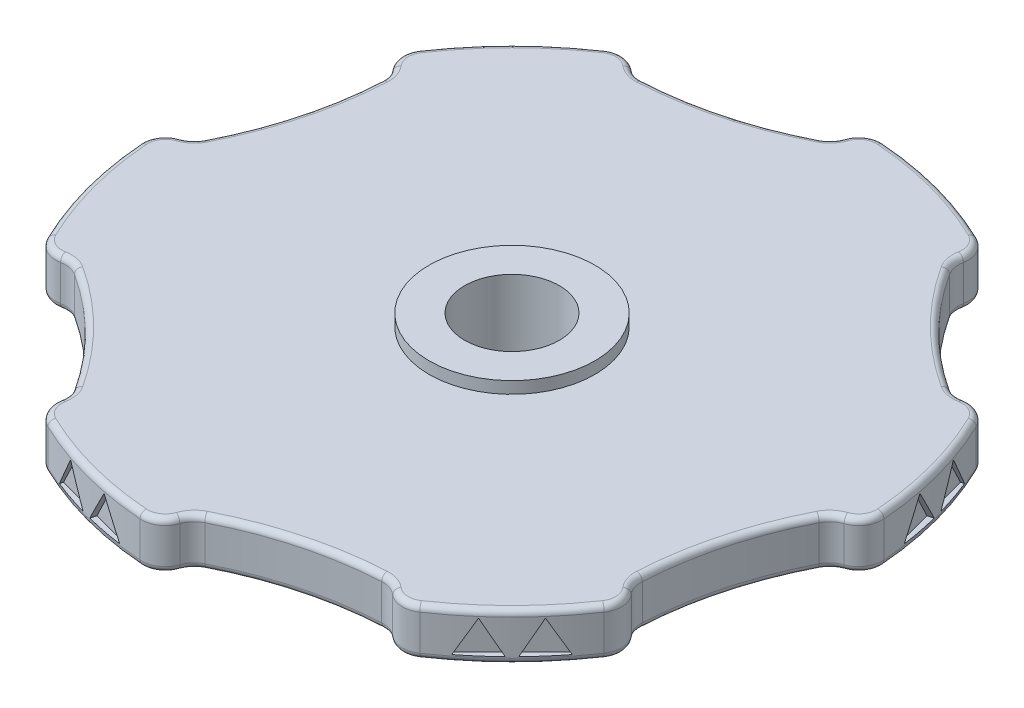
from build123d import *

# Parameters (mm, degrees)
EXTRUDE_2_DEPTH          = 4
FILLET_2_R               = 2
FILLET_1_R               = 0.5
SKETCH_2_R               = 4
CUT_EXTRUDE_1_DEPTH      = 5.0000001
EXTRUDE_START            = -5
SKETCH_4_R               = 7
SKETCH_4_R_2             = 4
EXTRUDE_3_DEPTH          = 6
CUT_EXTRUDE_2_DEPTH      = 0.5
PATTERN_CIRCULAR_3_COUNT = 6


with BuildPart() as part:
    # 草图1 → 凸台-拉伸2 (new body)
    with BuildSketch(Plane(origin=(0, 0, 0), x_dir=(1, 0, 0), z_dir=(0, 1, 0))):
        with BuildLine():
            ThreePointArc((-23.613697296, -13.633374491), (-25.201696191, -13.812934862), (-26.414260376, -12.7719399))
            ThreePointArc((-26.414260376, -12.7719399), (-28.340263743, -7.593750783), (-29.261390457, -2.146305779))
            ThreePointArc((-29.261390457, -2.146305779), (-28.731776551, -0.638495604), (-27.266748981, 0))
            Line((-27.266748981, 0), (0, 0))
            Line((0, 0), (-23.613697296, -13.633374491))
        make_face()
        with BuildLine():
            Line((0, 0), (-23.613697296, -13.633374491))
            ThreePointArc((-23.613697296, -13.633374491), (-18.014452987, -18.014452987), (-13.633374491, -23.613697296))
            Line((-13.633374491, -23.613697296), (0, 0))
        make_face()
        with BuildLine():
            Line((0, 0), (-13.633374491, -23.613697296))
            ThreePointArc((-13.633374491, -23.613697296), (-13.812934862, -25.201696191), (-12.7719399, -26.414260376))
            ThreePointArc((-12.7719399, -26.414260376), (-7.593750783, -28.340263743), (-2.146305779, -29.261390457))
            ThreePointArc((-2.146305779, -29.261390457), (-0.638495604, -28.731776551), (0, -27.266748981))
            Line((0, -27.266748981), (0, 0))
        make_face()
        with BuildLine():
            Line((0, 0), (0, -27.266748981))
            ThreePointArc((0, -27.266748981), (6.593747429, -24.608200416), (13.633374491, -23.613697296))
            Line((13.633374491, -23.613697296), (0, 0))
        make_face()
        with BuildLine():
            ThreePointArc((23.613697296, -13.633374491), (24.563200587, -14.918841688), (24.267954597, -16.489450558))
            ThreePointArc((24.267954597, -16.489450558), (20.74651296, -20.74651296), (16.489450558, -24.267954597))
            ThreePointArc((16.489450558, -24.267954597), (14.918841688, -24.563200587), (13.633374491, -23.613697296))
            Line((13.633374491, -23.613697296), (0, 0))
            Line((0, 0), (23.613697296, -13.633374491))
        make_face()
        with BuildLine():
            Line((0, 0), (23.613697296, -13.633374491))
            ThreePointArc((23.613697296, -13.633374491), (24.608200416, -6.593747429), (27.266748981, 0))
            Line((27.266748981, 0), (0, 0))
        make_face()
        with BuildLine():
            ThreePointArc((23.613697296, 13.633374491), (25.201696191, 13.812934862), (26.414260376, 12.7719399))
            ThreePointArc((26.414260376, 12.7719399), (28.340263743, 7.593750783), (29.261390457, 2.146305779))
            ThreePointArc((29.261390457, 2.146305779), (28.731776551, 0.638495604), (27.266748981, 0))
            Line((27.266748981, 0), (0, 0))
            Line((0, 0), (23.613697296, 13.633374491))
        make_face()
        with BuildLine():
            Line((0, 0), (23.613697296, 13.633374491))
            ThreePointArc((23.613697296, 13.633374491), (18.014452987, 18.014452987), (13.633374491, 23.613697296))
            Line((13.633374491, 23.613697296), (0, 0))
        make_face()
        with BuildLine():
            ThreePointArc((0, 27.266748981), (0.638495604, 28.731776551), (2.146305779, 29.261390457))
            ThreePointArc((2.146305779, 29.261390457), (7.593750783, 28.340263743), (12.7719399, 26.414260376))
            ThreePointArc((12.7719399, 26.414260376), (13.812934862, 25.201696191), (13.633374491, 23.613697296))
            Line((13.633374491, 23.613697296), (0, 0))
            Line((0, 0), (0, 27.266748981))
        make_face()
        with BuildLine():
            Line((0, 0), (0, 27.266748981))
            ThreePointArc((0, 27.266748981), (-6.593747429, 24.608200416), (-13.633374491, 23.613697296))
            Line((-13.633374491, 23.613697296), (0, 0))
        make_face()
        with BuildLine():
            ThreePointArc((-23.613697296, 13.633374491), (-24.563200587, 14.918841688), (-24.267954597, 16.489450558))
            ThreePointArc((-24.267954597, 16.489450558), (-20.74651296, 20.74651296), (-16.489450558, 24.267954597))
            ThreePointArc((-16.489450558, 24.267954597), (-14.918841688, 24.563200587), (-13.633374491, 23.613697296))
            Line((-13.633374491, 23.613697296), (0, 0))
            Line((0, 0), (-23.613697296, 13.633374491))
        make_face()
        with BuildLine():
            Line((0, 0), (-23.613697296, 13.633374491))
            ThreePointArc((-23.613697296, 13.633374491), (-24.608200416, 6.593747429), (-27.266748981, 0))
            Line((-27.266748981, 0), (0, 0))
        make_face()
    extrude(amount=EXTRUDE_2_DEPTH)

    # 圆角2
    fillet_2_edges = [part.edges().sort_by_distance(p)[0] for p in [
        (23.613697296, 2, 13.633374491),
        (13.633374491, 2, 23.613697296),
        (0, 2, 27.266748981),
        (-13.633374491, 2, 23.613697296),
        (-23.613697296, 2, 13.633374491),
        (-27.266748981, 2, 0),
        (-23.613697296, 2, -13.633374491),
        (-13.633374491, 2, -23.613697296),
        (0, 2, -27.266748981),
        (13.633374491, 2, -23.613697296),
        (23.613697296, 2, -13.633374491),
        (27.266748981, 2, 0),
    ]]
    fillet(fillet_2_edges, radius=FILLET_2_R)

    # 圆角1
    fillet_1_edges = [part.edges().sort_by_distance(p)[0] for p in [
        (24.608200416, 0, 6.593747429),
        (24.608200416, 4, 6.593747429),
        (24.610469164, 0, 15.251837855),
        (24.610469164, 4, 15.251837855),
        (13.402973244, 0, 23.753233217),
        (13.402973244, 4, 23.753233217),
        (0.269301293, 0, 27.27239001),
        (0.269301293, 4, 27.27239001),
        (-13.869416766, 0, 23.483931924),
        (-13.869416766, 4, 23.483931924),
        (-23.483931924, 0, 13.869416766),
        (20.74651296, 4, 20.74651296),
        (-23.483931924, 4, 13.869416766),
        (-27.27239001, 0, -0.269301293),
        (-27.27239001, 4, -0.269301293),
        (-23.753233217, 0, -13.402973244),
        (-23.753233217, 4, -13.402973244),
        (-13.402973244, 0, -23.753233217),
        (-13.402973244, 4, -23.753233217),
        (-0.269301293, 0, -27.27239001),
        (-0.269301293, 4, -27.27239001),
        (13.869416766, 0, -23.483931924),
        (13.869416766, 4, -23.483931924),
        (23.483931924, 0, -13.869416766),
        (23.483931924, 4, -13.869416766),
        (27.27239001, 0, 0.269301293),
        (27.27239001, 4, 0.269301293),
        (23.753233217, 0, 13.402973244),
        (23.753233217, 4, 13.402973244),
        (28.340263743, 4, -7.593750783),
        (20.74651296, 0, 20.74651296),
        (-7.593750783, 0, 28.340263743),
        (-28.340263743, 0, 7.593750783),
        (-20.74651296, 0, -20.74651296),
        (7.593750783, 0, -28.340263743),
        (7.593750783, 4, -28.340263743),
        (28.340263743, 0, -7.593750783),
        (-20.74651296, 4, -20.74651296),
        (-28.340263743, 4, 7.593750783),
        (15.251837855, 0, 24.610469164),
        (15.251837855, 4, 24.610469164),
        (6.593747429, 0, 24.608200416),
        (6.593747429, 4, 24.608200416),
        (-0.903244454, 0, 28.939210423),
        (-0.903244454, 4, 28.939210423),
        (-13.687372568, 0, 25.513713619),
        (-13.687372568, 4, 25.513713619),
        (-18.014452987, 0, 18.014452987),
        (-18.014452987, 4, 18.014452987),
        (-25.513713619, 0, 13.687372568),
        (-25.513713619, 4, 13.687372568),
        (-28.939210423, 0, 0.903244454),
        (-28.939210423, 4, 0.903244454),
        (-24.608200416, 0, -6.593747429),
        (-24.608200416, 4, -6.593747429),
        (-24.610469164, 0, -15.251837855),
        (-24.610469164, 4, -15.251837855),
        (-15.251837855, 0, -24.610469164),
        (-15.251837855, 4, -24.610469164),
        (-6.593747429, 0, -24.608200416),
        (-6.593747429, 4, -24.608200416),
        (0.903244454, 0, -28.939210423),
        (0.903244454, 4, -28.939210423),
        (-7.593750783, 4, 28.340263743),
        (13.687372568, 0, -25.513713619),
        (13.687372568, 4, -25.513713619),
        (18.014452987, 0, -18.014452987),
        (18.014452987, 4, -18.014452987),
        (25.513713619, 0, -13.687372568),
        (25.513713619, 4, -13.687372568),
        (28.939210423, 0, -0.903244454),
        (28.939210423, 4, -0.903244454),
    ]]
    fillet(fillet_1_edges, radius=FILLET_1_R)

    # 草图2 → 切除-拉伸1 (cut, through all)
    with BuildSketch(Plane.XZ):
        Circle(SKETCH_2_R)
    extrude(amount=-CUT_EXTRUDE_1_DEPTH, mode=Mode.SUBTRACT)

    # 草图4 → 凸台-拉伸3 (add)
    with BuildSketch(Plane(origin=(0, 4, 0), x_dir=(1, 0, 0), z_dir=(0, 1, 0)).offset(EXTRUDE_START)):
        Circle(SKETCH_4_R)
        Circle(SKETCH_4_R_2, mode=Mode.SUBTRACT)
    extrude(amount=EXTRUDE_3_DEPTH)

    # 草图7 → 切除-拉伸2 (cut)
    with BuildSketch(Plane(origin=(-7.593750783, 0, 28.340263743), x_dir=(0.965925826, 0, 0.258819045), z_dir=(-0.258819045, 0, 0.965925826))):
        Polygon((-2, 3.385640646), (-3.6, 0.614359354), (-0.4, 0.614359354), align=None)
        Polygon((3.6, 0.614359354), (2, 3.385640646), (0.4, 0.614359354), align=None)
    cut_extrude_2 = extrude(amount=-CUT_EXTRUDE_2_DEPTH, mode=Mode.SUBTRACT)

    # 阵列(圆周)3: 切除-拉伸2 ×6 about axis
    pattern_circular_3_axis = Axis((0, 0, 0), (0, 1, 0))
    for i in range(1, PATTERN_CIRCULAR_3_COUNT):
        add(cut_extrude_2.rotate(pattern_circular_3_axis, i * 360 / PATTERN_CIRCULAR_3_COUNT), mode=Mode.SUBTRACT)


solid = part.part
